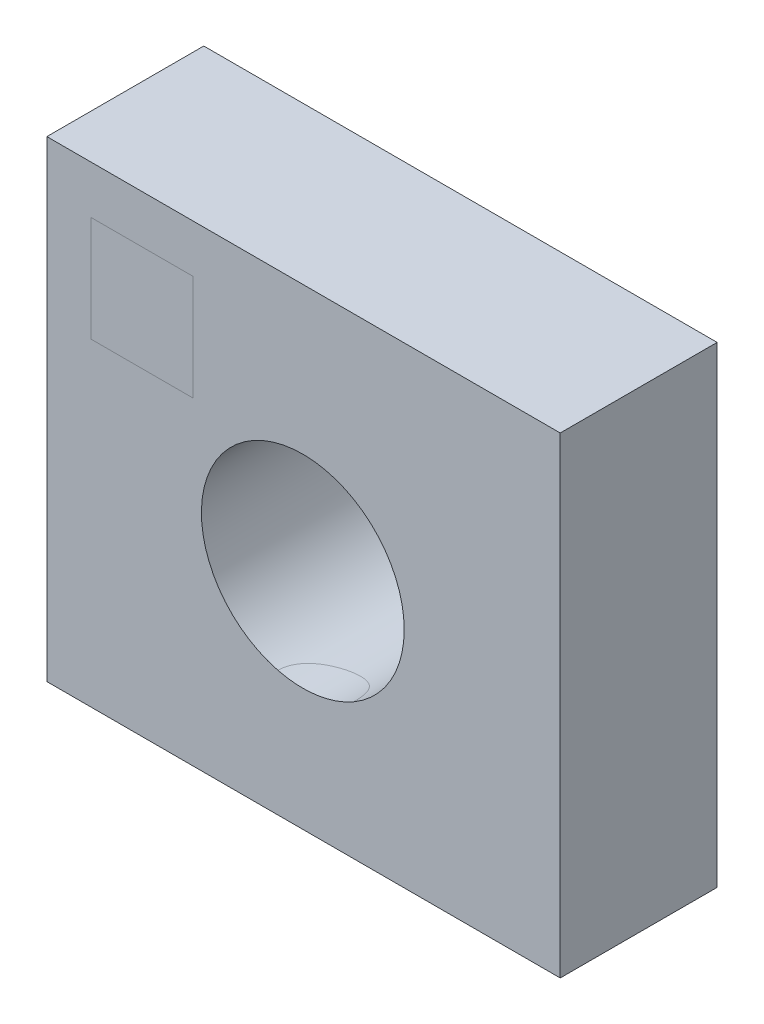
from build123d import *

# Parameters (mm, degrees)
SKIZZE1_W                       = 49.077966102
SKIZZE1_H                       = 45.125182164
AUFSATZ_LINEAR_AUSTRAGEN1_DEPTH = 15
SKIZZE2_R                       = 9.693306542
SCHNITT_LINEAR_AUSTRAGEN1_DEPTH = 16


with BuildPart() as part:
    # Skizze1 → Aufsatz-Linear austragen1 (new body)
    with BuildSketch(Plane.XY):
        with Locations((24.538983051, -1.183346479)):
            Rectangle(SKIZZE1_W, SKIZZE1_H)
    extrude(amount=AUFSATZ_LINEAR_AUSTRAGEN1_DEPTH)

    # Skizze2 → Schnitt-Linear austragen1 (cut, through all)
    with BuildSketch(Plane.XY.offset(15)):
        with Locations((24.468714324, -2.366676924)):
            Circle(SKIZZE2_R)
    extrude(amount=-SCHNITT_LINEAR_AUSTRAGEN1_DEPTH, mode=Mode.SUBTRACT)


solid = part.part
